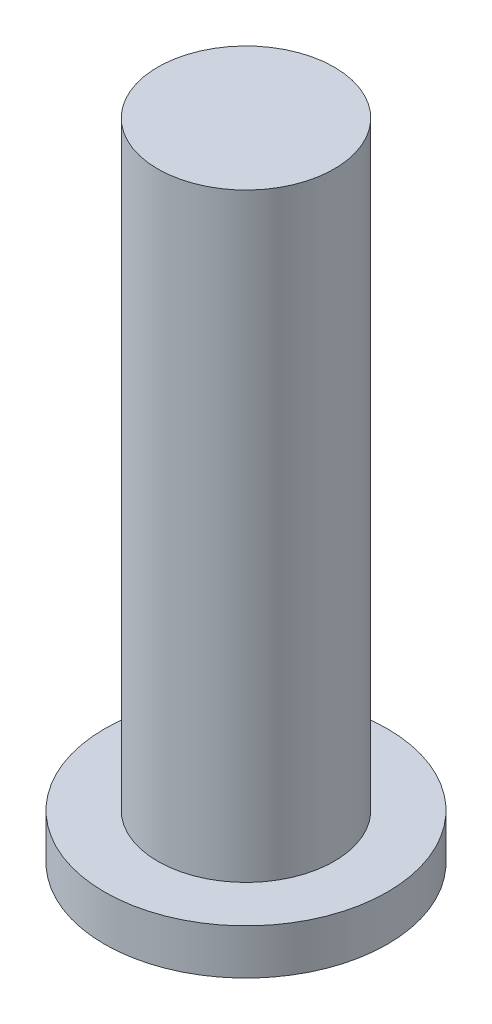
from build123d import *

# Parameters (mm, degrees)
SKETCH1_R           = 4.953
BOSS_EXTRUDE1_DEPTH = 33.655
SKETCH1_3_R         = 7.9375
BOSS_EXTRUDE2_DEPTH = 2.54


with BuildPart() as part:
    # Sketch1 → Boss-Extrude1 (new body)
    with BuildSketch(Plane(origin=(0, 0, 0), x_dir=(1, 0, 0), z_dir=(0, 1, 0))):
        Circle(SKETCH1_R)
    extrude(amount=BOSS_EXTRUDE1_DEPTH)

    # Sketch1_3 → Boss-Extrude2 (add)
    with BuildSketch(Plane(origin=(0, 0, 0), x_dir=(1, 0, 0), z_dir=(0, 1, 0))):
        Circle(SKETCH1_3_R)
    extrude(amount=-BOSS_EXTRUDE2_DEPTH)


solid = part.part
